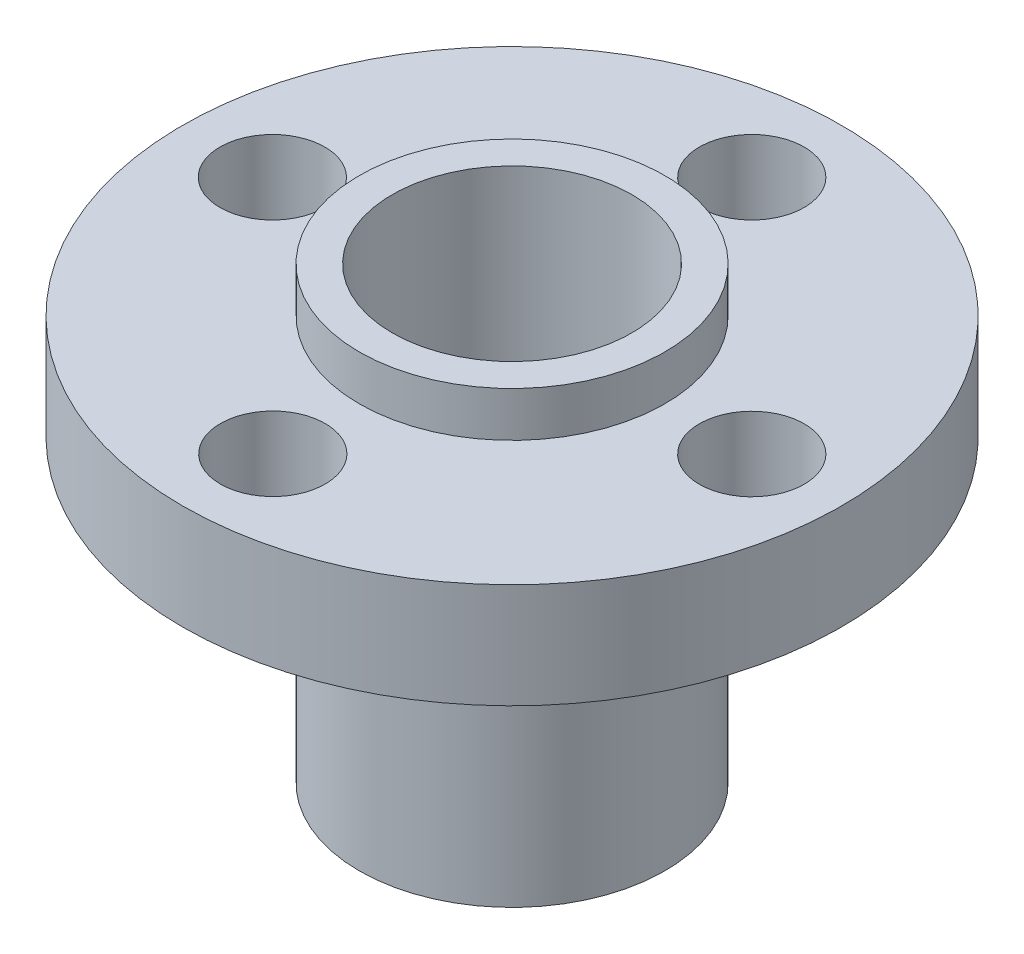
from build123d import *

# Parameters (mm, degrees)
SKETCH_1_R      = 11
SKETCH_1_R_2    = 1.75
SKETCH_1_R_3    = 4
EXTRUDE_2_DEPTH = 3.5
EXTRUDE_START   = -10
SKETCH_1_4_R    = 5.1
SKETCH_1_4_R_2  = 4
EXTRUDE_3_DEPTH = 10
SKETCH_1_5_R    = 5.1
SKETCH_1_5_R_2  = 4
EXTRUDE_4_DEPTH = 5


with BuildPart() as part:
    # 草图1 → 凸台-拉伸2 (new body)
    with BuildSketch(Plane(origin=(0, 0, 0), x_dir=(1, 0, 0), z_dir=(0, 1, 0))):
        with Locations((-9.890440024, 3.718512798)):
            Circle(SKETCH_1_R)
        with Locations((-9.890440024, -4.267967035)):
            Circle(SKETCH_1_R_2, mode=Mode.SUBTRACT)
        with Locations((-17.890440024, 3.718512798)):
            Circle(SKETCH_1_R_2, mode=Mode.SUBTRACT)
        with Locations((-1.890440024, 3.718512798)):
            Circle(SKETCH_1_R_2, mode=Mode.SUBTRACT)
        with Locations((-9.890440024, 11.718512798)):
            Circle(SKETCH_1_R_2, mode=Mode.SUBTRACT)
        with Locations((-9.890440024, 3.718512798)):
            Circle(SKETCH_1_R_3, mode=Mode.SUBTRACT)
    extrude(amount=EXTRUDE_2_DEPTH)

    # 草图1<4> → 凸台-拉伸3 (add)
    with BuildSketch(Plane(origin=(0, 0, 0), x_dir=(1, 0, 0), z_dir=(0, 1, 0)).offset(EXTRUDE_START)):
        with Locations((-9.890440024, 3.718512798)):
            Circle(SKETCH_1_4_R)
        with Locations((-9.890440024, 3.718512798)):
            Circle(SKETCH_1_4_R_2, mode=Mode.SUBTRACT)
    extrude(amount=EXTRUDE_3_DEPTH)

    # 草图1<5> → 凸台-拉伸4 (add)
    with BuildSketch(Plane(origin=(0, 0, 0), x_dir=(1, 0, 0), z_dir=(0, 1, 0))):
        with Locations((-9.890440024, 3.718512798)):
            Circle(SKETCH_1_5_R)
        with Locations((-9.890440024, 3.718512798)):
            Circle(SKETCH_1_5_R_2, mode=Mode.SUBTRACT)
    extrude(amount=EXTRUDE_4_DEPTH)


solid = part.part
